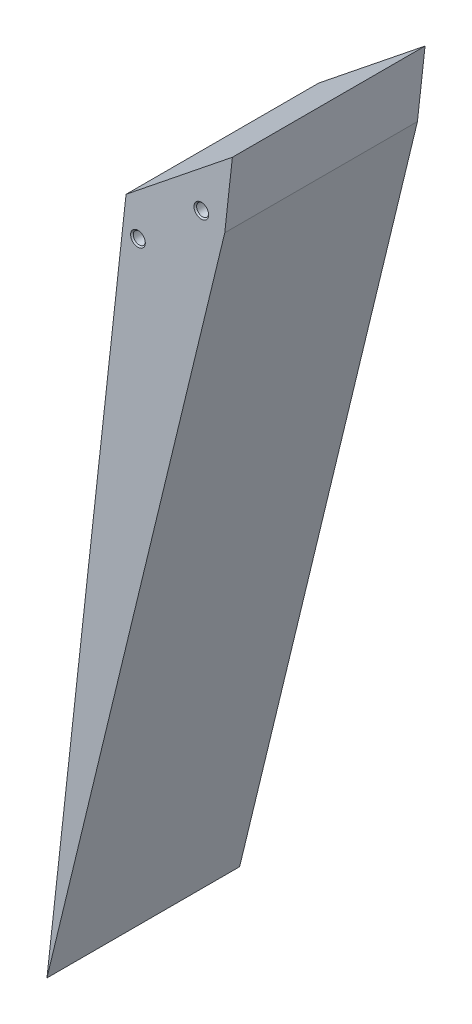
from build123d import *

# Parameters (mm, degrees)
EXTRUDE_1_DEPTH             = 40
HOLE_WIZARD_M3_1_AT_2_COUNT = 2
HOLE_WIZARD_M3_1_AT_2_PITCH = 17.556765078


with BuildPart() as part:
    # 草图1 → 凸台-拉伸1 (new body)
    with BuildSketch(Plane.XY):
        Polygon((8.237882641, -16.544998045), (-13.831826124, -34.234767829), (-30.256597299, -183.33281239), (6.654915402, -30.914593657), align=None)
    extrude(amount=EXTRUDE_1_DEPTH)

    # 草图5 → M3 螺纹孔1 (revolve, cut)
    with BuildSketch(Plane(origin=(-11.358047282, -41.00286285, 40), x_dir=(0, -1, 0), z_dir=(1, 0, 0))):
        Polygon((0, 0), (0, 8.251075774), (1.25, 7.5), (1.25, 0.275), (1.525, 0), align=None)
    hole_wizard_m3_1 = revolve(axis=Axis((-11.358047282, -41.00286285, 46.35), (0, 0, -1)), mode=Mode.SUBTRACT)

    # M3 螺纹孔1 at 2: M3 螺纹孔1 ×2
    with Locations(*[Vector(0.749142925, 0.662408392, 0) * (i * HOLE_WIZARD_M3_1_AT_2_PITCH) for i in range(1, HOLE_WIZARD_M3_1_AT_2_COUNT)]):
        add(hole_wizard_m3_1, mode=Mode.SUBTRACT)

    # 镜向1: M3 螺纹孔1 across plane
    add(hole_wizard_m3_1.mirror(Plane.XY.offset(20)), mode=Mode.SUBTRACT)

    # 镜向1 copy 1 sketch → 镜向1 copy 1 (revolve, cut)
    with BuildSketch(Plane(origin=(1.794479058, -29.373114321, 0), x_dir=(0, -1, 0), z_dir=(1, 0, 0))):
        Polygon((0, 0), (0, -8.251075774), (1.25, -7.5), (1.25, -0.275), (1.525, 0), align=None)
    revolve(axis=Axis((1.794479058, -29.373114321, -6.35), (0, 0, -1)), mode=Mode.SUBTRACT)


solid = part.part
